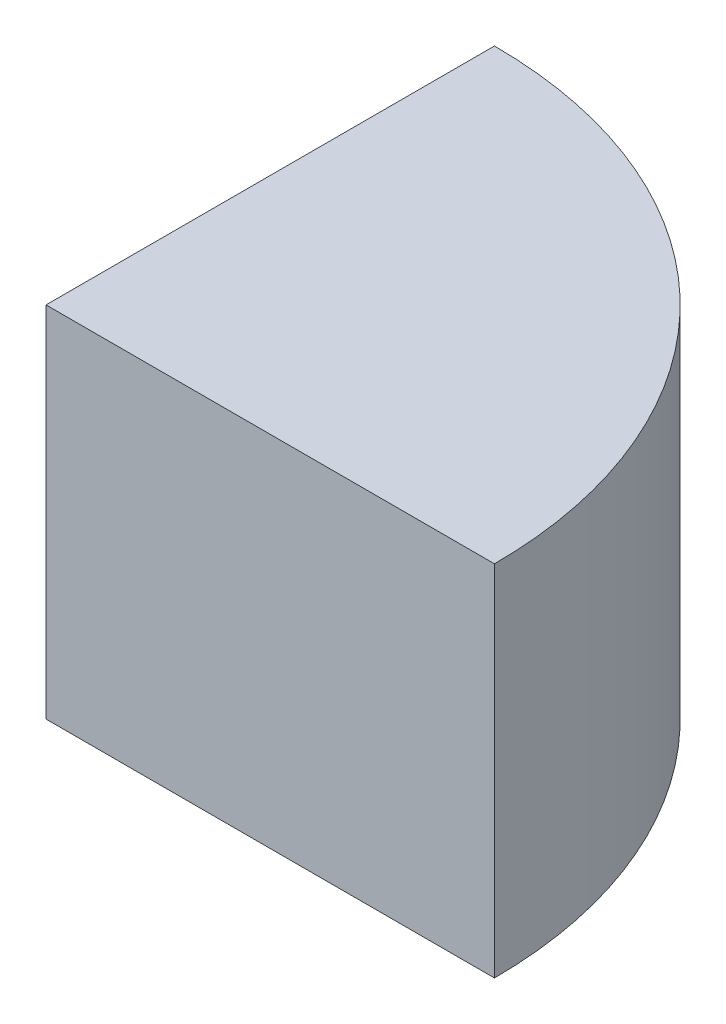
from build123d import *

# Parameters (mm, degrees)
EXTRUDE_1_DEPTH = 28


with BuildPart() as part:
    # 草圖1 → 填料-伸長1 (new body)
    with BuildSketch(Plane(origin=(0, 0, 0), x_dir=(1, 0, 0), z_dir=(0, 1, 0))):
        with BuildLine():
            Line((0, 35), (0, 0))
            Line((0, 0), (35, 0))
            ThreePointArc((35, 0), (24.748737342, 24.748737342), (0, 35))
        make_face()
    extrude(amount=EXTRUDE_1_DEPTH)


solid = part.part
